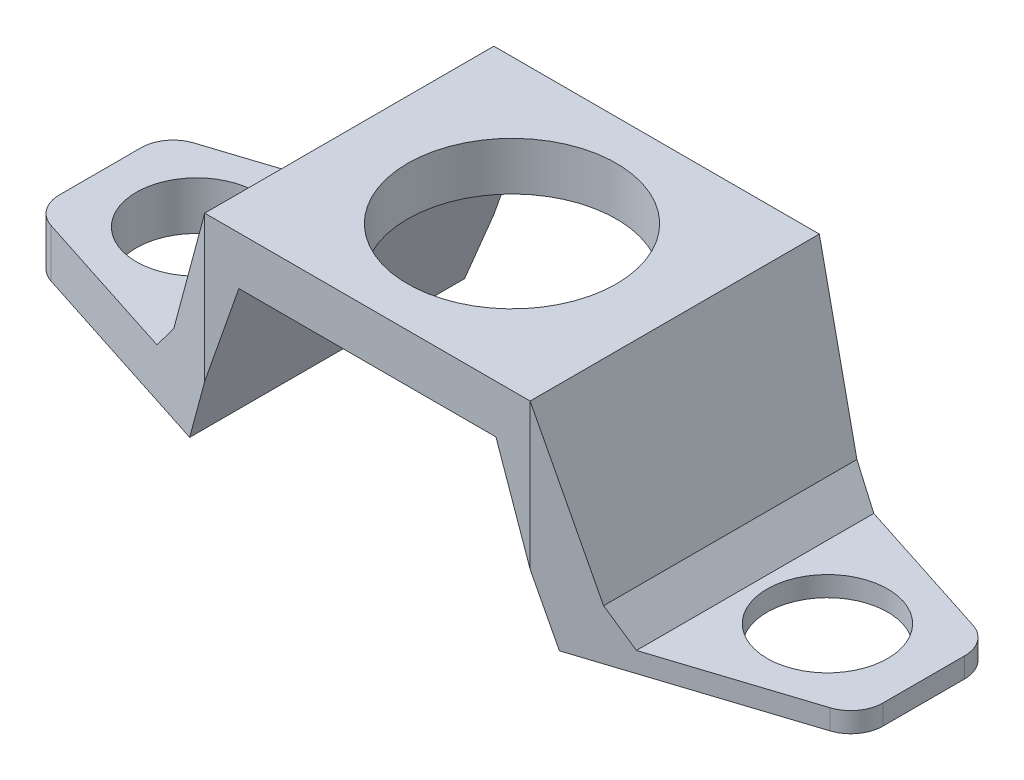
from build123d import *
from OCP.BRepFilletAPI import BRepFilletAPI_MakeChamfer

# Parameters (mm, degrees)
BOSS_EXTRUDE1_DEPTH = 9
CUT_EXTRUDE1_REACH  = 32.118
SKETCH2_R           = 6.5
CUT_EXTRUDE2_DEPTH  = 18
CUT_EXTRUDE3_REACH  = 30.95
SKETCH4_R           = 3.7499999999999996
CUT_EXTRUDE4_DEPTH  = 10
FILLET1_R           = 2
CHAMFER1_SIZE       = 2
CHAMFER1_SIZE2      = 0.8842438837908889
CHAMFER1_SIZE2_2    = 0.8842438837908887


with BuildPart() as part:
    # Sketch1 → Boss-Extrude1 (new, symmetric)
    with BuildSketch(Plane.XY):
        Polygon((-25.633576548445145, 1e-17), (-11.506423451554879, 4e-17), (-8, 10), (0, 9.999999999999993), (8, 9.999999999999993), (11.506423451554879, 4e-17), (25.633576548445145, 4e-17), (25.63357654844514, 3.000000000000001), (13.633576548445141, 3), (10.12715309689026, 13.000000000000002), (0, 12.999999999999995), (-10.127153096890261, 13.000000000000002), (-13.633576548445141, 3), (-25.633576548445145, 3), align=None)
    extrude(amount=BOSS_EXTRUDE1_DEPTH, both=True)

    # Sketch2 → Cut-Extrude1 (cut, up to next)
    with BuildSketch(Plane(origin=(8.91e-15, 12.999999999999995, 0), x_dir=(1, -7.1e-16, 0), z_dir=(7.1e-16, 1, 0)), mode=Mode.PRIVATE) as cut_extrude1_sk1:
        with Locations(Location((0, 0, 0), (0, 0, 180))):
            Circle(SKETCH2_R)
    cut_extrude1_tool1 = extrude(cut_extrude1_sk1.sketch, amount=-CUT_EXTRUDE1_REACH, mode=Mode.PRIVATE) & part.part
    add(cut_extrude1_tool1.solids().sort_by_distance((0, 13, 0))[0], mode=Mode.SUBTRACT)

    # Sketch3 → Cut-Extrude2 (cut)
    with BuildSketch(Plane(origin=(8.91e-15, 12.999999999999995, 0), x_dir=(1, -7.1e-16, 0), z_dir=(7.1e-16, 1, 0))):
        Polygon((-10.12715309689027, 9), (-25.63357654844515, 4), (-25.63357654844515, 9), align=None)
        Polygon((-10.12715309689025, -9), (-25.63357654844515, -4), (-25.63357654844515, -9), align=None)
        Polygon((25.63357654844515, 9), (10.12715309689025, 9), (25.63357654844515, 4), align=None)
        Polygon((25.63357654844515, -4), (25.63357654844515, -9), (10.12715309689025, -9), align=None)
    extrude(amount=-CUT_EXTRUDE2_DEPTH, mode=Mode.SUBTRACT)

    # Sketch4 → Cut-Extrude3 (cut, up to next)
    with BuildSketch(Plane(origin=(0, 3, 0), x_dir=(1, 0, 0), z_dir=(0, 1, 0)), mode=Mode.PRIVATE) as cut_extrude3_sk1:
        with Locations(Location((-19.633576548445145, -2.4e-15, 0), (0, 0, 270))):
            Circle(SKETCH4_R)
    cut_extrude3_tool1 = extrude(cut_extrude3_sk1.sketch, amount=-CUT_EXTRUDE3_REACH, mode=Mode.PRIVATE) & part.part
    # Sketch4 → Cut-Extrude3 (cut, up to next)
    with BuildSketch(Plane(origin=(0, 3, 0), x_dir=(1, 0, 0), z_dir=(0, 1, 0)), mode=Mode.PRIVATE) as cut_extrude3_sk2:
        with Locations(Location((19.63357654844515, 2.4e-15, 0), (0, 0, 270))):
            Circle(SKETCH4_R)
    cut_extrude3_tool2 = extrude(cut_extrude3_sk2.sketch, amount=-CUT_EXTRUDE3_REACH, mode=Mode.PRIVATE) & part.part
    add(cut_extrude3_tool1.solids().sort_by_distance((-19.633577, 3, 0))[0], mode=Mode.SUBTRACT)
    add(cut_extrude3_tool2.solids().sort_by_distance((19.633577, 3, 0))[0], mode=Mode.SUBTRACT)

    # Sketch5 → Cut-Extrude4 (cut, symmetric)
    with BuildSketch(Plane.XY):
        Polygon((13.633576548445141, 3), (14.247200652467244, 1.2500000000000009), (25.63357654844515, 1.2500000000000009), (25.633576548445152, 3.000000000000001), align=None)
    extrude(amount=CUT_EXTRUDE4_DEPTH, both=True, mode=Mode.SUBTRACT)

    # Fillet1
    fillet1_edges = [part.edges().sort_by_distance(p)[0] for p in [
        (25.633576548445152, 0.6250000000000018, 4),
        (-25.633576548445145, 1.5, -4),
        (-25.633576548445145, 1.5, 4),
        (25.633576548445152, 0.6250000000000018, -4),
    ]]
    fillet(fillet1_edges, radius=FILLET1_R)

    # Chamfer1: one chamfer whose edges measure the first distance from different faces: ONE call of the kernel's chamfer builder (chamfer() names one face for all edges)
    chamfer1_edges_1 = [part.edges().sort_by_distance(p)[0] for p in [
        (14.247200652467244, 1.2500000000000009, 0),
    ]]
    chamfer1_side_1 = [part.faces().sort_by_distance(p)[0] for p in [
        (12.132458042687091, 7.281053120074241, 1.1e-16),
    ]]
    chamfer1_edges_2 = [part.edges().sort_by_distance(p)[0] for p in [
        (-13.633576548445141, 3, -3.55e-15),
    ]]
    chamfer1_side_2 = [part.faces().sort_by_distance(p)[0] for p in [
        (-11.841196306073245, 8.111705038297892, -3.84e-15),
    ]]
    chamfer1 = BRepFilletAPI_MakeChamfer(part.part.solid().wrapped)
    for e in chamfer1_edges_1:
        chamfer1.Add(CHAMFER1_SIZE, CHAMFER1_SIZE2, e.wrapped, chamfer1_side_1[0].wrapped)  # the first distance lies on this face
    for e in chamfer1_edges_2:
        chamfer1.Add(CHAMFER1_SIZE, CHAMFER1_SIZE2_2, e.wrapped, chamfer1_side_2[0].wrapped)  # the first distance lies on this face
    add(Compound.cast(chamfer1.Shape()), mode=Mode.REPLACE)


solid = part.part
